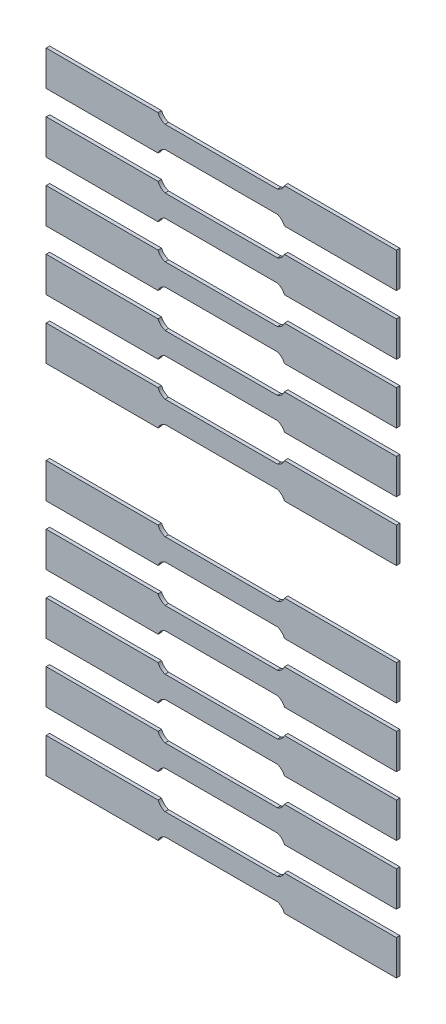
from build123d import *

# Parameters (mm, degrees)
BOSS_EXTRUDE1_DEPTH    = 1
BOSS_EXTRUDE1_2_DEPTH  = 1
BOSS_EXTRUDE1_3_DEPTH  = 1
BOSS_EXTRUDE1_4_DEPTH  = 1
BOSS_EXTRUDE1_5_DEPTH  = 1
BOSS_EXTRUDE1_6_DEPTH  = 1
BOSS_EXTRUDE1_7_DEPTH  = 1
BOSS_EXTRUDE1_8_DEPTH  = 1
BOSS_EXTRUDE1_9_DEPTH  = 1
BOSS_EXTRUDE1_10_DEPTH = 1


with BuildPart() as part:
    # Sketch1 → Boss-Extrude1 (new body)
    with BuildSketch(Plane.XY):
        with BuildLine():
            Line((0, 10), (0, 0))
            Line((0, 0), (31.955983327, 0))
            ThreePointArc((31.955983327, 0), (32.748426731, 1.158893702), (33.955983327, 1.875))
            Line((33.955983327, 1.875), (34, 1.875))
            Line((34, 1.875), (50, 1.875))
            Line((50, 1.875), (66, 1.875))
            Line((66, 1.875), (66.044016673, 1.875))
            ThreePointArc((66.044016673, 1.875), (67.251573269, 1.158893702), (68.044016673, 0))
            Line((68.044016673, 0), (100, 0))
            Line((100, 0), (100, 10))
            Line((100, 10), (68.044016673, 10))
            ThreePointArc((68.044016673, 10), (67.251573269, 8.841106298), (66.044016673, 8.125))
            Line((66.044016673, 8.125), (66, 8.125))
            Line((66, 8.125), (49.955983327, 8.125))
            Line((49.955983327, 8.125), (33.955983327, 8.125))
            ThreePointArc((33.955983327, 8.125), (32.748426731, 8.841106298), (31.955983327, 10))
            Line((31.955983327, 10), (0, 10))
        make_face()
    extrude(amount=-BOSS_EXTRUDE1_DEPTH)


with BuildPart() as body_2:
    # Sketch1 → Boss-Extrude1 2 (new body)
    with BuildSketch(Plane.XY):
        with BuildLine():
            Line((0, 27), (0, 17))
            Line((0, 17), (31.955983327, 17))
            ThreePointArc((31.955983327, 17), (32.748426731, 18.158893702), (33.955983327, 18.875))
            Line((33.955983327, 18.875), (34, 18.875))
            Line((34, 18.875), (50, 18.875))
            Line((50, 18.875), (66, 18.875))
            Line((66, 18.875), (66.044016673, 18.875))
            ThreePointArc((66.044016673, 18.875), (67.251573269, 18.158893702), (68.044016673, 17))
            Line((68.044016673, 17), (100, 17))
            Line((100, 17), (100, 27))
            Line((100, 27), (68.044016673, 27))
            ThreePointArc((68.044016673, 27), (67.251573269, 25.841106298), (66.044016673, 25.125))
            Line((66.044016673, 25.125), (66, 25.125))
            Line((66, 25.125), (49.955983327, 25.125))
            Line((49.955983327, 25.125), (33.955983327, 25.125))
            ThreePointArc((33.955983327, 25.125), (32.748426731, 25.841106298), (31.955983327, 27))
            Line((31.955983327, 27), (0, 27))
        make_face()
    extrude(amount=-BOSS_EXTRUDE1_2_DEPTH)


with BuildPart() as body_3:
    # Sketch1 → Boss-Extrude1 3 (new body)
    with BuildSketch(Plane.XY):
        with BuildLine():
            Line((0, 44), (0, 34))
            Line((0, 34), (31.955983327, 34))
            ThreePointArc((31.955983327, 34), (32.748426731, 35.158893702), (33.955983327, 35.875))
            Line((33.955983327, 35.875), (34, 35.875))
            Line((34, 35.875), (50, 35.875))
            Line((50, 35.875), (66, 35.875))
            Line((66, 35.875), (66.044016673, 35.875))
            ThreePointArc((66.044016673, 35.875), (67.251573269, 35.158893702), (68.044016673, 34))
            Line((68.044016673, 34), (100, 34))
            Line((100, 34), (100, 44))
            Line((100, 44), (68.044016673, 44))
            ThreePointArc((68.044016673, 44), (67.251573269, 42.841106298), (66.044016673, 42.125))
            Line((66.044016673, 42.125), (66, 42.125))
            Line((66, 42.125), (49.955983327, 42.125))
            Line((49.955983327, 42.125), (33.955983327, 42.125))
            ThreePointArc((33.955983327, 42.125), (32.748426731, 42.841106298), (31.955983327, 44))
            Line((31.955983327, 44), (0, 44))
        make_face()
    extrude(amount=-BOSS_EXTRUDE1_3_DEPTH)


with BuildPart() as body_4:
    # Sketch1 → Boss-Extrude1 4 (new body)
    with BuildSketch(Plane.XY):
        with BuildLine():
            Line((0, 61), (0, 51))
            Line((0, 51), (31.955983327, 51))
            ThreePointArc((31.955983327, 51), (32.748426731, 52.158893702), (33.955983327, 52.875))
            Line((33.955983327, 52.875), (34, 52.875))
            Line((34, 52.875), (50, 52.875))
            Line((50, 52.875), (66, 52.875))
            Line((66, 52.875), (66.044016673, 52.875))
            ThreePointArc((66.044016673, 52.875), (67.251573269, 52.158893702), (68.044016673, 51))
            Line((68.044016673, 51), (100, 51))
            Line((100, 51), (100, 61))
            Line((100, 61), (68.044016673, 61))
            ThreePointArc((68.044016673, 61), (67.251573269, 59.841106298), (66.044016673, 59.125))
            Line((66.044016673, 59.125), (66, 59.125))
            Line((66, 59.125), (49.955983327, 59.125))
            Line((49.955983327, 59.125), (33.955983327, 59.125))
            ThreePointArc((33.955983327, 59.125), (32.748426731, 59.841106298), (31.955983327, 61))
            Line((31.955983327, 61), (0, 61))
        make_face()
    extrude(amount=-BOSS_EXTRUDE1_4_DEPTH)


with BuildPart() as body_5:
    # Sketch1 → Boss-Extrude1 5 (new body)
    with BuildSketch(Plane.XY):
        with BuildLine():
            Line((0, 78), (0, 68))
            Line((0, 68), (31.955983327, 68))
            ThreePointArc((31.955983327, 68), (32.748426731, 69.158893702), (33.955983327, 69.875))
            Line((33.955983327, 69.875), (34, 69.875))
            Line((34, 69.875), (50, 69.875))
            Line((50, 69.875), (66, 69.875))
            Line((66, 69.875), (66.044016673, 69.875))
            ThreePointArc((66.044016673, 69.875), (67.251573269, 69.158893702), (68.044016673, 68))
            Line((68.044016673, 68), (100, 68))
            Line((100, 68), (100, 78))
            Line((100, 78), (68.044016673, 78))
            ThreePointArc((68.044016673, 78), (67.251573269, 76.841106298), (66.044016673, 76.125))
            Line((66.044016673, 76.125), (66, 76.125))
            Line((66, 76.125), (49.955983327, 76.125))
            Line((49.955983327, 76.125), (33.955983327, 76.125))
            ThreePointArc((33.955983327, 76.125), (32.748426731, 76.841106298), (31.955983327, 78))
            Line((31.955983327, 78), (0, 78))
        make_face()
    extrude(amount=-BOSS_EXTRUDE1_5_DEPTH)


with BuildPart() as body_6:
    # Sketch1 → Boss-Extrude1 6 (new body)
    with BuildSketch(Plane.XY):
        with BuildLine():
            Line((0, 112), (0, 102))
            Line((0, 102), (31.955983327, 102))
            ThreePointArc((31.955983327, 102), (32.748426731, 103.158893702), (33.955983327, 103.875))
            Line((33.955983327, 103.875), (34, 103.875))
            Line((34, 103.875), (50, 103.875))
            Line((50, 103.875), (66, 103.875))
            Line((66, 103.875), (66.044016673, 103.875))
            ThreePointArc((66.044016673, 103.875), (67.251573269, 103.158893702), (68.044016673, 102))
            Line((68.044016673, 102), (100, 102))
            Line((100, 102), (100, 112))
            Line((100, 112), (68.044016673, 112))
            ThreePointArc((68.044016673, 112), (67.251573269, 110.841106298), (66.044016673, 110.125))
            Line((66.044016673, 110.125), (66, 110.125))
            Line((66, 110.125), (49.955983327, 110.125))
            Line((49.955983327, 110.125), (33.955983327, 110.125))
            ThreePointArc((33.955983327, 110.125), (32.748426731, 110.841106298), (31.955983327, 112))
            Line((31.955983327, 112), (0, 112))
        make_face()
    extrude(amount=-BOSS_EXTRUDE1_6_DEPTH)


with BuildPart() as body_7:
    # Sketch1 → Boss-Extrude1 7 (new body)
    with BuildSketch(Plane.XY):
        with BuildLine():
            Line((0, 129), (0, 119))
            Line((0, 119), (31.955983327, 119))
            ThreePointArc((31.955983327, 119), (32.748426731, 120.158893702), (33.955983327, 120.875))
            Line((33.955983327, 120.875), (34, 120.875))
            Line((34, 120.875), (50, 120.875))
            Line((50, 120.875), (66, 120.875))
            Line((66, 120.875), (66.044016673, 120.875))
            ThreePointArc((66.044016673, 120.875), (67.251573269, 120.158893702), (68.044016673, 119))
            Line((68.044016673, 119), (100, 119))
            Line((100, 119), (100, 129))
            Line((100, 129), (68.044016673, 129))
            ThreePointArc((68.044016673, 129), (67.251573269, 127.841106298), (66.044016673, 127.125))
            Line((66.044016673, 127.125), (66, 127.125))
            Line((66, 127.125), (49.955983327, 127.125))
            Line((49.955983327, 127.125), (33.955983327, 127.125))
            ThreePointArc((33.955983327, 127.125), (32.748426731, 127.841106298), (31.955983327, 129))
            Line((31.955983327, 129), (0, 129))
        make_face()
    extrude(amount=-BOSS_EXTRUDE1_7_DEPTH)


with BuildPart() as body_8:
    # Sketch1 → Boss-Extrude1 8 (new body)
    with BuildSketch(Plane.XY):
        with BuildLine():
            Line((0, 146), (0, 136))
            Line((0, 136), (31.955983327, 136))
            ThreePointArc((31.955983327, 136), (32.748426731, 137.158893702), (33.955983327, 137.875))
            Line((33.955983327, 137.875), (34, 137.875))
            Line((34, 137.875), (50, 137.875))
            Line((50, 137.875), (66, 137.875))
            Line((66, 137.875), (66.044016673, 137.875))
            ThreePointArc((66.044016673, 137.875), (67.251573269, 137.158893702), (68.044016673, 136))
            Line((68.044016673, 136), (100, 136))
            Line((100, 136), (100, 146))
            Line((100, 146), (68.044016673, 146))
            ThreePointArc((68.044016673, 146), (67.251573269, 144.841106298), (66.044016673, 144.125))
            Line((66.044016673, 144.125), (66, 144.125))
            Line((66, 144.125), (49.955983327, 144.125))
            Line((49.955983327, 144.125), (33.955983327, 144.125))
            ThreePointArc((33.955983327, 144.125), (32.748426731, 144.841106298), (31.955983327, 146))
            Line((31.955983327, 146), (0, 146))
        make_face()
    extrude(amount=-BOSS_EXTRUDE1_8_DEPTH)


with BuildPart() as body_9:
    # Sketch1 → Boss-Extrude1 9 (new body)
    with BuildSketch(Plane.XY):
        with BuildLine():
            Line((0, 163), (0, 153))
            Line((0, 153), (31.955983327, 153))
            ThreePointArc((31.955983327, 153), (32.748426731, 154.158893702), (33.955983327, 154.875))
            Line((33.955983327, 154.875), (34, 154.875))
            Line((34, 154.875), (50, 154.875))
            Line((50, 154.875), (66, 154.875))
            Line((66, 154.875), (66.044016673, 154.875))
            ThreePointArc((66.044016673, 154.875), (67.251573269, 154.158893702), (68.044016673, 153))
            Line((68.044016673, 153), (100, 153))
            Line((100, 153), (100, 163))
            Line((100, 163), (68.044016673, 163))
            ThreePointArc((68.044016673, 163), (67.251573269, 161.841106298), (66.044016673, 161.125))
            Line((66.044016673, 161.125), (66, 161.125))
            Line((66, 161.125), (49.955983327, 161.125))
            Line((49.955983327, 161.125), (33.955983327, 161.125))
            ThreePointArc((33.955983327, 161.125), (32.748426731, 161.841106298), (31.955983327, 163))
            Line((31.955983327, 163), (0, 163))
        make_face()
    extrude(amount=-BOSS_EXTRUDE1_9_DEPTH)


with BuildPart() as body_10:
    # Sketch1 → Boss-Extrude1 10 (new body)
    with BuildSketch(Plane.XY):
        with BuildLine():
            Line((0, 180), (0, 170))
            Line((0, 170), (31.955983327, 170))
            ThreePointArc((31.955983327, 170), (32.748426731, 171.158893702), (33.955983327, 171.875))
            Line((33.955983327, 171.875), (34, 171.875))
            Line((34, 171.875), (50, 171.875))
            Line((50, 171.875), (66, 171.875))
            Line((66, 171.875), (66.044016673, 171.875))
            ThreePointArc((66.044016673, 171.875), (67.251573269, 171.158893702), (68.044016673, 170))
            Line((68.044016673, 170), (100, 170))
            Line((100, 170), (100, 180))
            Line((100, 180), (68.044016673, 180))
            ThreePointArc((68.044016673, 180), (67.251573269, 178.841106298), (66.044016673, 178.125))
            Line((66.044016673, 178.125), (66, 178.125))
            Line((66, 178.125), (49.955983327, 178.125))
            Line((49.955983327, 178.125), (33.955983327, 178.125))
            ThreePointArc((33.955983327, 178.125), (32.748426731, 178.841106298), (31.955983327, 180))
            Line((31.955983327, 180), (0, 180))
        make_face()
    extrude(amount=-BOSS_EXTRUDE1_10_DEPTH)


solid = Compound([part.part, body_2.part, body_3.part, body_4.part, body_5.part, body_6.part, body_7.part, body_8.part, body_9.part, body_10.part])
